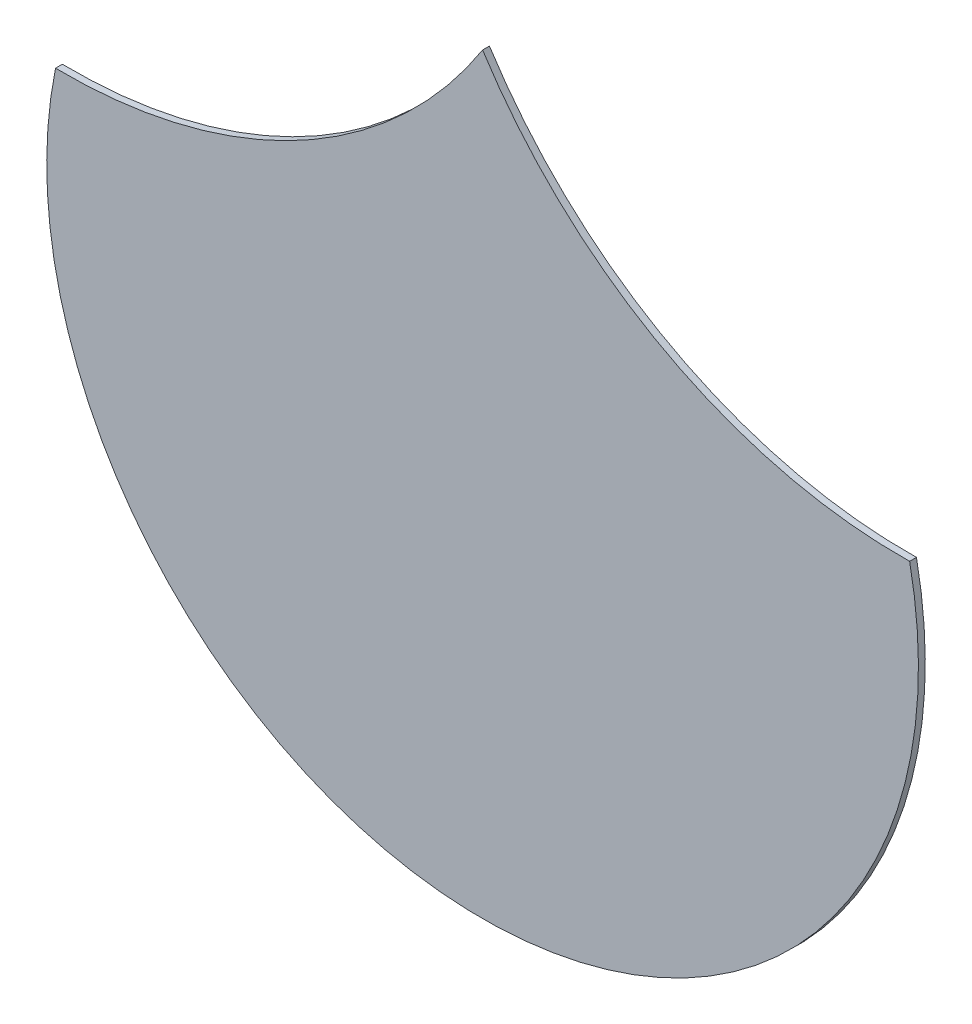
from build123d import *

# Parameters (mm, degrees)
SALIENTE_EXTRUIR1_DEPTH = 0.1


with BuildPart() as part:
    # Model → Saliente-Extruir1 (new body)
    with BuildSketch(Plane.XY):
        with BuildLine():
            ThreePointArc((25.050014064, 16.649571004), (31.300014064, 8.994456696), (37.550014064, 16.649571004))
            ThreePointArc((37.550014064, 16.649571004), (33.988270313, 17.514237911), (31.300014064, 20.00561218))
            ThreePointArc((31.300014064, 20.00561218), (28.611757815, 17.514237911), (25.050014064, 16.649571004))
        make_face()
    extrude(amount=SALIENTE_EXTRUIR1_DEPTH)


solid = part.part
